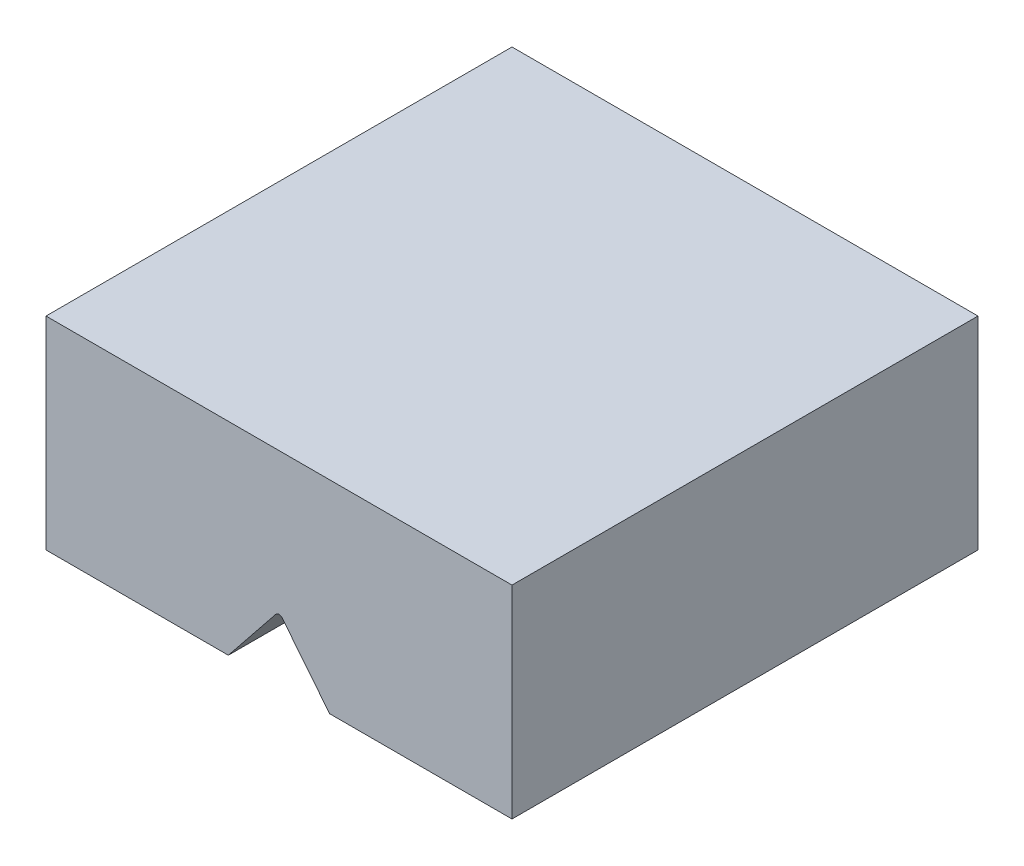
from build123d import *

# Parameters (mm, degrees)
SKETCH1_W           = 23
SKETCH1_H           = 23
BOSS_EXTRUDE1_DEPTH = 10
CUT_EXTRUDE1_DEPTH  = 24
SKETCH3_R           = 2.2
CUT_EXTRUDE2_DEPTH  = 5.3


with BuildPart() as part:
    # Sketch1 → Boss-Extrude1 (new body)
    with BuildSketch(Plane(origin=(0, 0, 0), x_dir=(1, 0, 0), z_dir=(0, 1, 0))):
        Rectangle(SKETCH1_W, SKETCH1_H)
    extrude(amount=BOSS_EXTRUDE1_DEPTH)

    # Sketch2 → Cut-Extrude1 (cut, through all)
    with BuildSketch(Plane.XY.offset(11.5)):
        with BuildLine():
            Line((-2.5, 0), (-0.15607285, 2.925065045))
            ThreePointArc((-0.15607285, 2.925065045), (0, 3), (0.15607285, 2.925065045))
            Line((0.15607285, 2.925065045), (2.5, 0))
            Line((2.5, 0), (-2.5, 0))
        make_face()
    extrude(amount=-CUT_EXTRUDE1_DEPTH, mode=Mode.SUBTRACT)

    # Sketch3 → Cut-Extrude2 (cut)
    with BuildSketch(Plane.XZ):
        Circle(SKETCH3_R)
    extrude(amount=-CUT_EXTRUDE2_DEPTH, mode=Mode.SUBTRACT)


solid = part.part
